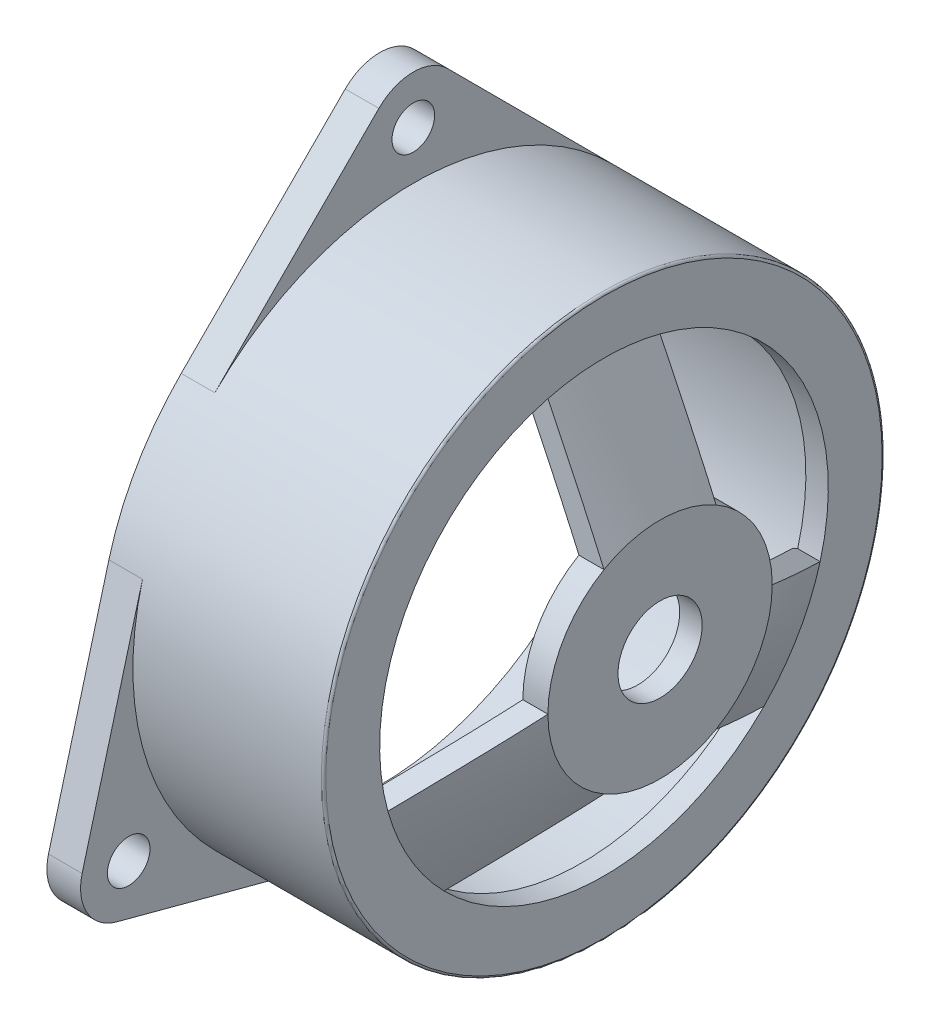
from build123d import *

# Parameters (mm, degrees)
SKETCH3_R           = 25.4
SKETCH1_R           = 50.8
SKETCH4_R           = 63.5
BOSS_EXTRUDE1_DEPTH = 50.8
SHELL1_T            = -5.08
CUT_EXTRUDE1_DEPTH  = 50.8
SKETCH6_R           = 4.826
BOSS_EXTRUDE3_DEPTH = 7.62
FILLET1_R           = 0.508
SKETCH7_R           = 9.525
CUT_EXTRUDE2_DEPTH  = 124.861079859
CIRPATTERN2_COUNT   = 3


with BuildPart() as part:
    # Sketch3 → Loft1 section 0
    with BuildSketch(Plane(origin=(12.7, 0, 0), x_dir=(0, 0, -1), z_dir=(1, 0, 0))):
        Circle(SKETCH3_R)
    # Sketch1 → Loft1 section 1
    with BuildSketch(Plane(origin=(0, 0, 0), x_dir=(0, 0, -1), z_dir=(1, 0, 0))):
        Circle(SKETCH1_R)
    loft()

    # Sketch4 → Boss-Extrude1 (add)
    with BuildSketch(Plane.ZY):
        Circle(SKETCH4_R)
    extrude(amount=BOSS_EXTRUDE1_DEPTH)

    # Shell1
    shell1_openings = [part.faces().sort_by_distance(p)[0] for p in [
        (-50.8, 0, 0),
    ]]
    offset(amount=SHELL1_T, openings=shell1_openings, kind=Kind.INTERSECTION)

    # Sketch5 → Cut-Extrude1 (cut)
    with BuildSketch(Plane(origin=(12.7, 0, 0), x_dir=(0, 0, -1), z_dir=(1, 0, 0))):
        with BuildLine():
            Line((-12.7, 21.997045256), (-12.7, 49.186888497))
            ThreePointArc((-12.7, 49.186888497), (-43.994090512, 25.4), (-48.947094971, -13.59492162))
            Line((-48.947094971, -13.59492162), (-25.4, 0))
            ThreePointArc((-25.4, 0), (-21.997045256, 12.7), (-12.7, 21.997045256))
        make_face()
        with BuildLine():
            Line((12.7, 21.997045256), (12.7, 49.186888497))
            ThreePointArc((12.7, 49.186888497), (43.994090512, 25.4), (48.947094971, -13.59492162))
            Line((48.947094971, -13.59492162), (25.4, 0))
            ThreePointArc((25.4, 0), (21.997045256, 12.7), (12.7, 21.997045256))
        make_face()
        with BuildLine():
            Line((12.7, -21.997045256), (36.247094971, -35.591966876))
            ThreePointArc((36.247094971, -35.591966876), (0, -50.8), (-36.247094971, -35.591966876))
            Line((-36.247094971, -35.591966876), (-12.7, -21.997045256))
            ThreePointArc((-12.7, -21.997045256), (0, -25.4), (12.7, -21.997045256))
        make_face()
    extrude(amount=-CUT_EXTRUDE1_DEPTH, mode=Mode.SUBTRACT)

    # Sketch6 → Boss-Extrude3 (add)
    with BuildSketch(Plane.ZY.offset(50.8)):
        with BuildLine():
            ThreePointArc((7.762367521, 82.105471512), (0.023010453, 85.305702571), (-7.729809299, 82.138225256))
            Line((-7.729809299, 82.138225256), (-44.940751738, 44.861774744))
            ThreePointArc((-44.940751738, 44.861774744), (0, 63.5), (44.940751738, 44.861774744))
            Line((44.940751738, 44.861774744), (7.79520225, 82.072717183))
            ThreePointArc((7.79520225, 82.072717183), (7.778802125, 82.089111629), (7.762367521, 82.105471512))
        make_face()
        with Locations((0, 74.422)):
            Circle(SKETCH6_R, mode=Mode.SUBTRACT)
    boss_extrude3 = extrude(amount=-BOSS_EXTRUDE3_DEPTH)

    # Fillet1
    fillet1_edges = [part.edges().sort_by_distance(p)[0] for p in [
        (0, 0, -63.5),
    ]]
    fillet(fillet1_edges, radius=FILLET1_R)

    # Sketch7 → Cut-Extrude2 (cut, through all)
    with BuildSketch(Plane(origin=(12.7, 0, 0), x_dir=(0, 0, -1), z_dir=(1, 0, 0))):
        Circle(SKETCH7_R)
    extrude(amount=-CUT_EXTRUDE2_DEPTH, mode=Mode.SUBTRACT)

    # CirPattern2: Boss-Extrude3 ×3 about axis
    cirpattern2_axis = Axis((0, 0, 0), (1, 0, 0))
    for i in range(1, CIRPATTERN2_COUNT):
        add(boss_extrude3.rotate(cirpattern2_axis, i * 360 / CIRPATTERN2_COUNT))


solid = part.part
